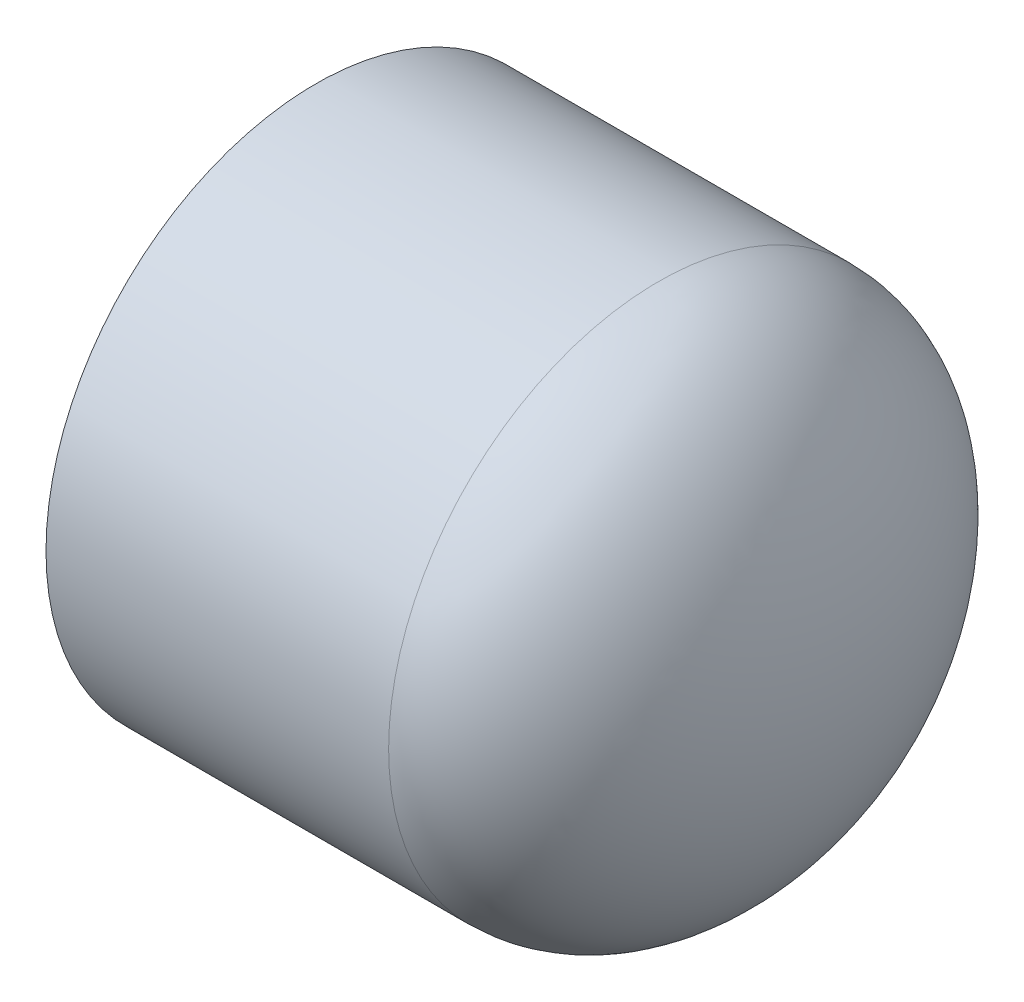
from build123d import *


with BuildPart() as part:
    # Sketch1 → Revolve1 (revolve)
    with BuildSketch(Plane.XY):
        with BuildLine():
            Line((19.827875, 0), (23.8125, 0))
            add(Edge.make_bspline(
                [(7.9375, -25.003125), (23.8125, -25.003125), (23.8125, 0)],
                knots=[3.141592654, 3.141592654, 3.141592654, 4.71238898, 4.71238898, 4.71238898], degree=2, weights=[1, 0.707106781, 1]))
            Line((7.9375, -25.003125), (-23.8125, -25.003125))
            Line((-23.8125, -25.003125), (-23.8125, -21.082))
            Line((-23.8125, -21.082), (7.9375, -21.0185))
            add(Edge.make_bspline(
                [(7.9375, -21.0185), (19.827875, -21.0185), (19.827875, 0)],
                knots=[0, 0, 0, 1.570796327, 1.570796327, 1.570796327], degree=2, weights=[1, 0.707106781, 1]))
        make_face()
    revolve(axis=Axis((-23.8125, 0, 0), (1, 0, 0)))


solid = part.part
